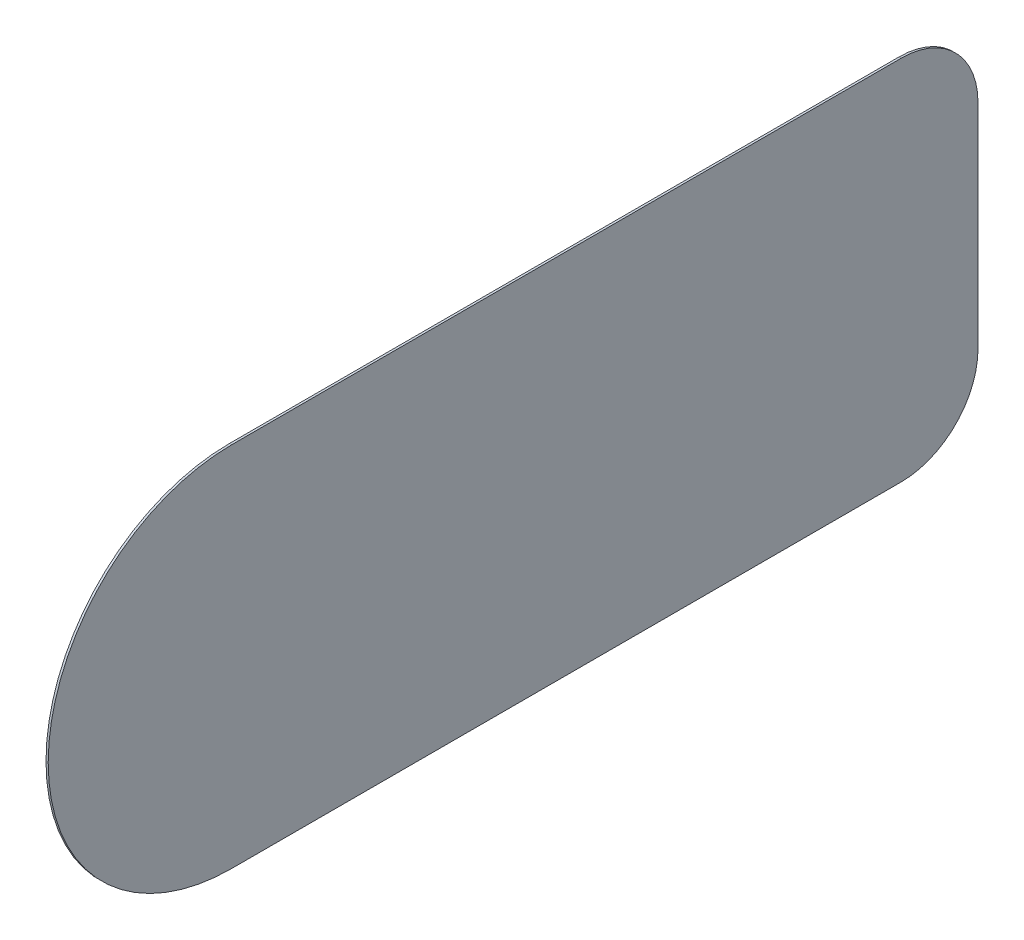
from build123d import *

# Parameters (mm, degrees)
BOSS_EXTRUDE1_DEPTH = 10


with BuildPart() as part:
    # Sketch2 → Boss-Extrude1 (new body)
    with BuildSketch(Plane(origin=(0, 0, 0), x_dir=(0, 0, -1), z_dir=(1, 0, 0))):
        with BuildLine():
            Line((0, 0), (3050, 0))
            ThreePointArc((3050, 0), (3297.487373415, 102.512626585), (3400, 350))
            Line((3400, 350), (3400, 1322))
            ThreePointArc((3400, 1322), (3297.487373415, 1569.487373415), (3050, 1672))
            Line((3050, 1672), (0, 1672))
            ThreePointArc((0, 1672), (-836, 836), (0, 0))
        make_face()
    extrude(amount=BOSS_EXTRUDE1_DEPTH)


solid = part.part
